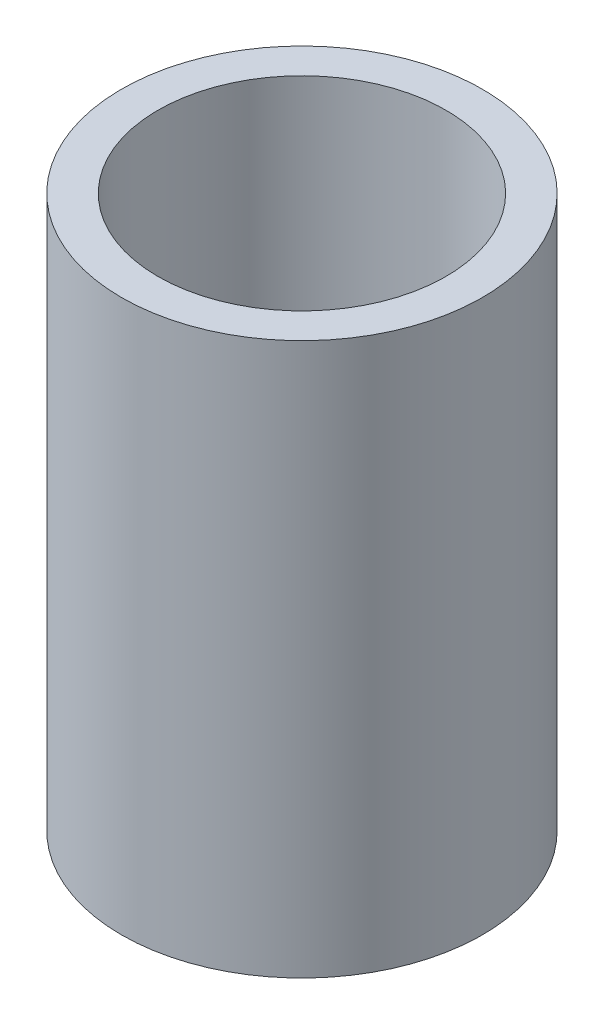
from build123d import *

# Parameters (mm, degrees)
SKETCH1_R           = 13.49375
SKETCH1_R_2         = 10.7696
BOSS_EXTRUDE2_DEPTH = 20.6375
SKETCH4_R           = 10.7696
SKETCH4_R_2         = 8.001
BOSS_EXTRUDE4_DEPTH = 0.79375


with BuildPart() as part:
    # Sketch1 → Boss-Extrude2 (new body, symmetric)
    with BuildSketch(Plane(origin=(0, 0, 0), x_dir=(1, 0, 0), z_dir=(0, 1, 0))):
        Circle(SKETCH1_R)
        Circle(SKETCH1_R_2, mode=Mode.SUBTRACT)
    extrude(amount=BOSS_EXTRUDE2_DEPTH, both=True)

    # Sketch4 → Boss-Extrude4 (add, symmetric)
    with BuildSketch(Plane(origin=(0, 0, 0), x_dir=(1, 0, 0), z_dir=(0, 1, 0))):
        Circle(SKETCH4_R)
        Circle(SKETCH4_R_2, mode=Mode.SUBTRACT)
    extrude(amount=BOSS_EXTRUDE4_DEPTH, both=True)


solid = part.part
